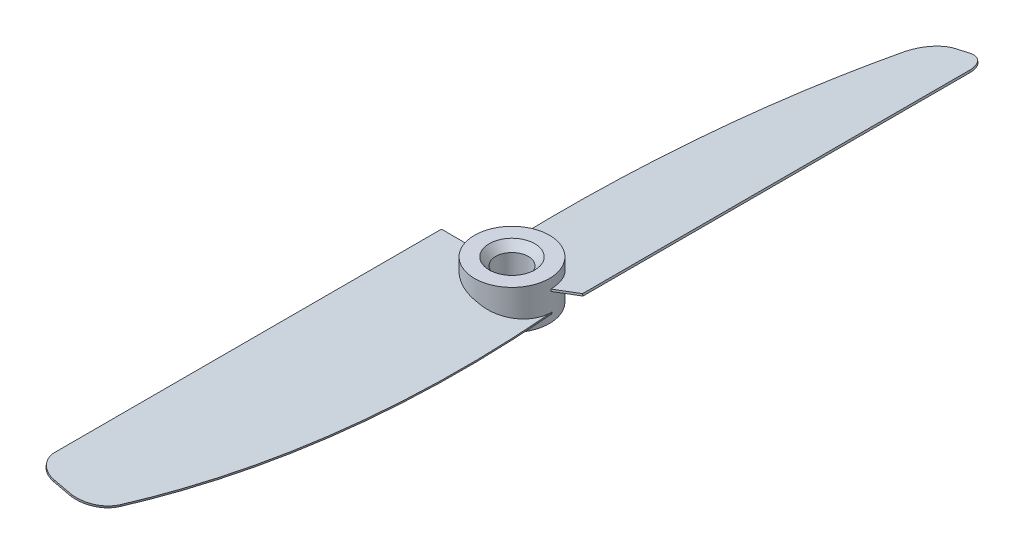
from build123d import *

# Parameters (mm, degrees)
SKETCH2_R             = 5.75
BOSS_EXTRUDE1_DEPTH   = 3
BOSS_EXTRUDE2_DEPTH   = 0.15
CIRPATTERN1_COUNT     = 2
SKETCH5_R             = 2.5
CUT_EXTRUDE1_DEPTH    = 7.0000001
CHAMFER1_SIZE         = 1
CHAMFER1_SIZE2        = 1.191753593
CHAMFER1_PART_2_SIZE  = 1
CHAMFER1_PART_2_SIZE2 = 1.191753593


with BuildPart() as part:
    # Sketch2 → Boss-Extrude1 (new body, symmetric)
    with BuildSketch(Plane(origin=(0, 0, 0), x_dir=(1, 0, 0), z_dir=(0, 1, 0))):
        Circle(SKETCH2_R)
    extrude(amount=BOSS_EXTRUDE1_DEPTH, both=True)

    # Sketch4 → Boss-Extrude2 (add, symmetric)
    with BuildSketch(Plane(origin=(0, 0, 0), x_dir=(0.974370065, -0.224951054, 0), z_dir=(-0.224951054, -0.974370065, 0))):
        with BuildLine():
            Line((-4.927774709, 0), (-9.991003068, 1.124716583))
            Line((-9.991003068, 1.124716583), (-9.991003068, 60.5))
            ThreePointArc((-9.991003068, 60.5), (-9.112323412, 62.621320344), (-6.991003068, 63.5))
            Line((-6.991003068, 63.5), (-4.215686073, 63.5))
            ThreePointArc((-4.215686073, 63.5), (-1.599645431, 62.426082199), (0.015394976, 60.10474367))
            add(Edge.make_bspline(
                [(6.277481036, 0), (7.695955288, 19.970569662), (6.360815362, 41.03083372), (0.015394976, 60.10474367)],
                knots=[0, 0, 0, 0, 0.936918572, 0.936918572, 0.936918572, 0.936918572], degree=3))
            add(Edge.make_bspline(
                [(6.277481036, 0), (6.277481036, 5.75), (0.674853163, 5.75), (-4.927774709, 5.75), (-4.927774709, 0)],
                knots=[4.71238898, 4.71238898, 4.71238898, 6.283185307, 6.283185307, 7.853981634, 7.853981634, 7.853981634], degree=2, weights=[1, 0.707106781, 1, 0.707106781, 1]))
        make_face()
    boss_extrude2 = extrude(amount=BOSS_EXTRUDE2_DEPTH, both=True)

    # CirPattern1: Boss-Extrude2 ×2 about axis
    cirpattern1_axis = Axis((0, 3, 0), (0, -1, 0))
    for i in range(1, CIRPATTERN1_COUNT):
        add(boss_extrude2.rotate(cirpattern1_axis, i * 360 / CIRPATTERN1_COUNT))

    # Sketch5 → Cut-Extrude1 (cut, through all)
    with BuildSketch(Plane(origin=(0, 3, 0), x_dir=(1, 0, 0), z_dir=(0, 1, 0))):
        Circle(SKETCH5_R)
    extrude(amount=-CUT_EXTRUDE1_DEPTH, mode=Mode.SUBTRACT)

    # Chamfer1
    chamfer1_edges = [part.edges().sort_by_distance(p)[0] for p in [
        (-2.5, -3, 0),
    ]]
    chamfer1_side = [part.faces().sort_by_distance(p)[0] for p in [
        (-2.5, 0, 0),
    ]]
    chamfer(chamfer1_edges, length=CHAMFER1_SIZE, length2=CHAMFER1_SIZE2, reference=chamfer1_side[0])

    # Chamfer1 part 2
    chamfer1_part_2_edges = [part.edges().sort_by_distance(p)[0] for p in [
        (-2.5, 3, 0),
    ]]
    chamfer1_part_2_side = [part.faces().sort_by_distance(p)[0] for p in [
        (-5.58736544, 3, 0),
    ]]
    chamfer(chamfer1_part_2_edges, length=CHAMFER1_PART_2_SIZE, length2=CHAMFER1_PART_2_SIZE2, reference=chamfer1_part_2_side[0])


solid = part.part
